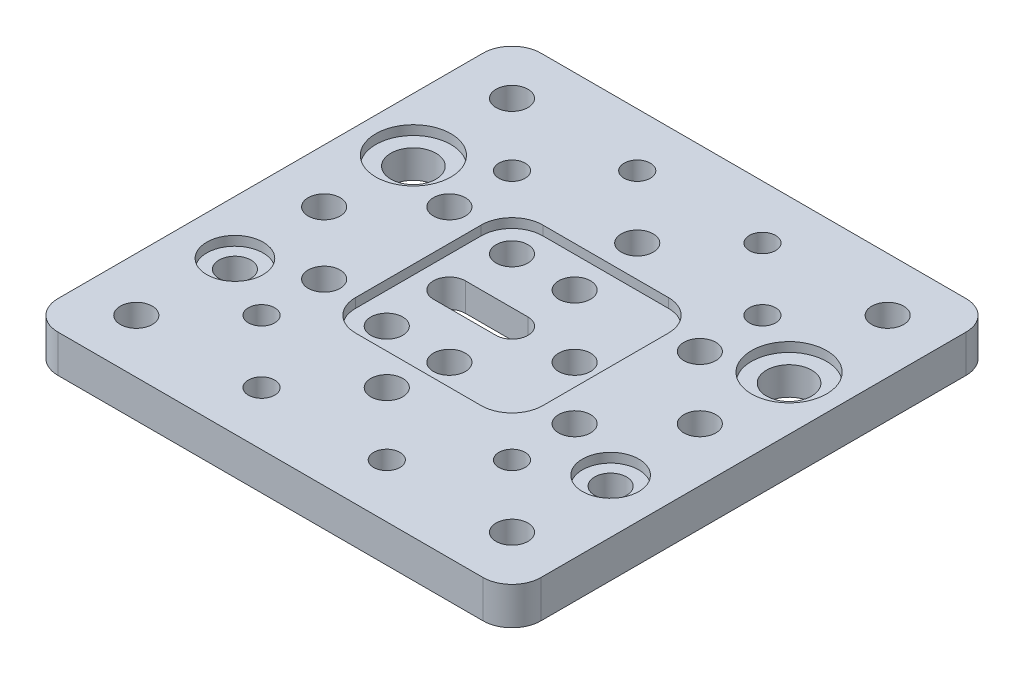
from build123d import *

# Parameters (mm, degrees)
SKETCH1_R             = 3.6
SKETCH1_R_2           = 2.55
BOSS_EXTRUDE1_DEPTH   = 6
M5X0_8_TAPPED_HOLE1_D = 4.2
SKETCH2_R             = 6
SKETCH2_R_2           = 4.5
CUT_EXTRUDE1_DEPTH    = 1.5


with BuildPart() as part:
    # Sketch1 → Boss-Extrude1 (new body)
    with BuildSketch(Plane(origin=(0, 0, 0), x_dir=(1, 0, 0), z_dir=(0, 1, 0))):
        with BuildLine():
            Line((33.94, -38.575), (-33.94, -38.575))
            ThreePointArc((-33.94, -38.575), (-37.217439931, -37.217439931), (-38.575, -33.94))
            Line((-38.575, -33.94), (-38.575, 33.94))
            ThreePointArc((-38.575, 33.94), (-37.217439931, 37.217439931), (-33.94, 38.575))
            Line((-33.94, 38.575), (33.94, 38.575))
            ThreePointArc((33.94, 38.575), (37.217439931, 37.217439931), (38.575, 33.94))
            Line((38.575, 33.94), (38.575, -33.94))
            ThreePointArc((38.575, -33.94), (37.217439931, -37.217439931), (33.94, -38.575))
        make_face()
        with Locations((-30, 14.25)):
            Circle(SKETCH1_R, mode=Mode.SUBTRACT)
        with Locations((-20, 10)):
            Circle(SKETCH1_R_2, mode=Mode.SUBTRACT)
        with Locations((0, 20)):
            Circle(SKETCH1_R_2, mode=Mode.SUBTRACT)
        with Locations((0, 10)):
            Circle(SKETCH1_R_2, mode=Mode.SUBTRACT)
        with Locations((-10, 10)):
            Circle(SKETCH1_R_2, mode=Mode.SUBTRACT)
        with Locations((-30, 30)):
            Circle(SKETCH1_R_2, mode=Mode.SUBTRACT)
        with Locations((-30, 0)):
            Circle(SKETCH1_R_2, mode=Mode.SUBTRACT)
        with Locations((30, 30)):
            Circle(SKETCH1_R_2, mode=Mode.SUBTRACT)
        with Locations((30, 14.25)):
            Circle(SKETCH1_R, mode=Mode.SUBTRACT)
        with Locations((30, 0)):
            Circle(SKETCH1_R_2, mode=Mode.SUBTRACT)
        with Locations((20, 10)):
            Circle(SKETCH1_R_2, mode=Mode.SUBTRACT)
        with Locations((20, -10)):
            Circle(SKETCH1_R_2, mode=Mode.SUBTRACT)
        with Locations((-30, -30)):
            Circle(SKETCH1_R_2, mode=Mode.SUBTRACT)
        with Locations((30, -30)):
            Circle(SKETCH1_R_2, mode=Mode.SUBTRACT)
        with Locations((-20, -10)):
            Circle(SKETCH1_R_2, mode=Mode.SUBTRACT)
        with Locations((0, -20)):
            Circle(SKETCH1_R_2, mode=Mode.SUBTRACT)
        with Locations((0, -10)):
            Circle(SKETCH1_R_2, mode=Mode.SUBTRACT)
        with Locations((-10, -10)):
            Circle(SKETCH1_R_2, mode=Mode.SUBTRACT)
        with Locations((10, 0)):
            Circle(SKETCH1_R_2, mode=Mode.SUBTRACT)
        with Locations((30, -14.25)):
            Circle(SKETCH1_R_2, mode=Mode.SUBTRACT)
        with Locations((-30, -14.25)):
            Circle(SKETCH1_R_2, mode=Mode.SUBTRACT)
        with BuildLine():
            Line((0, -2.55), (-10, -2.55))
            ThreePointArc((-10, -2.55), (-12.55, 0), (-10, 2.55))
            Line((-10, 2.55), (0, 2.55))
            ThreePointArc((0, 2.55), (2.55, 0), (0, -2.55))
        make_face(mode=Mode.SUBTRACT)
    extrude(amount=BOSS_EXTRUDE1_DEPTH)

    # M5x0.8 Tapped Hole1 (through all)
    with Locations(Plane(origin=(0, 6, 0), x_dir=(1, 0, 0), z_dir=(0, 1, 0))):
        with Locations((-20, 20), (-10, 30), (10, 30), (20, 20), (20, -20), (10, -30), (-10, -30), (-20, -20)):
            Hole(M5X0_8_TAPPED_HOLE1_D / 2)

    # Sketch2 → Cut-Extrude1 (cut)
    with BuildSketch(Plane(origin=(0, 6, 0), x_dir=(1, 0, 0), z_dir=(0, 1, 0))):
        with Locations((-30, 14.25)):
            Circle(SKETCH2_R)
        with Locations((30, 14.25)):
            Circle(SKETCH2_R)
        with Locations((30, -14.25)):
            Circle(SKETCH2_R_2)
        with Locations((-30, -14.25)):
            Circle(SKETCH2_R_2)
        with BuildLine():
            Line((10.03, -14.95), (-10.03, -14.95))
            ThreePointArc((-10.03, -14.95), (-13.508965363, -13.508965363), (-14.95, -10.03))
            Line((-14.95, -10.03), (-14.95, 10.03))
            ThreePointArc((-14.95, 10.03), (-13.508965363, 13.508965363), (-10.03, 14.95))
            Line((-10.03, 14.95), (10.03, 14.95))
            ThreePointArc((10.03, 14.95), (13.508965363, 13.508965363), (14.95, 10.03))
            Line((14.95, 10.03), (14.95, -10.03))
            ThreePointArc((14.95, -10.03), (13.508965363, -13.508965363), (10.03, -14.95))
        make_face()
    extrude(amount=-CUT_EXTRUDE1_DEPTH, mode=Mode.SUBTRACT)


solid = part.part
